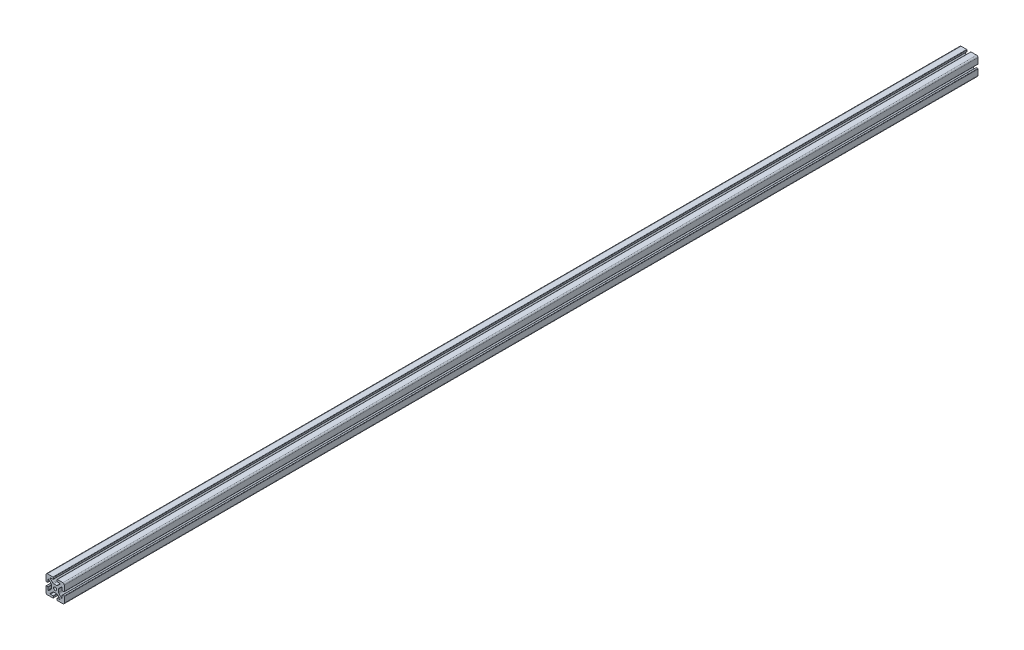
from build123d import *

# Parameters (mm, degrees)
SKETCH1_R           = 3.4036
BOSS_EXTRUDE1_DEPTH = 1000


with BuildPart() as part:
    # Sketch1 → Boss-Extrude1 (new body, symmetric)
    with BuildSketch(Plane.XY):
        with BuildLine():
            Line((-20, 16.952), (-20, 4.7625))
            ThreePointArc((-20, 4.7625), (-19.776815367, 4.223684633), (-19.238, 4.0005))
            Line((-19.238, 4.0005), (-16.2662, 4.0005))
            ThreePointArc((-16.2662, 4.0005), (-15.727384633, 4.223684633), (-15.5042, 4.7625))
            Line((-15.5042, 4.7625), (-15.5042, 10.2235))
            ThreePointArc((-15.5042, 10.2235), (-15.033804775, 10.927496204), (-14.203384633, 10.762315367))
            Line((-14.203384633, 10.762315367), (-8.635059555, 5.19399029))
            ThreePointArc((-8.635059555, 5.19399029), (-7.985348265, 4.221628629), (-7.7572, 3.074649845))
            Line((-7.7572, 3.074649845), (-7.7572, -3.074649845))
            ThreePointArc((-7.7572, -3.074649845), (-7.985348265, -4.221628629), (-8.635059555, -5.19399029))
            Line((-8.635059555, -5.19399029), (-14.203384633, -10.762315367))
            ThreePointArc((-14.203384633, -10.762315367), (-15.033804775, -10.927496204), (-15.5042, -10.2235))
            Line((-15.5042, -10.2235), (-15.5042, -4.7625))
            ThreePointArc((-15.5042, -4.7625), (-15.727384633, -4.223684633), (-16.2662, -4.0005))
            Line((-16.2662, -4.0005), (-19.238, -4.0005))
            ThreePointArc((-19.238, -4.0005), (-19.776815367, -4.223684633), (-20, -4.7625))
            Line((-20, -4.7625), (-20, -16.952))
            ThreePointArc((-20, -16.952), (-19.107261469, -19.107261469), (-16.952, -20))
            Line((-16.952, -20), (-4.7625, -20))
            ThreePointArc((-4.7625, -20), (-4.223684633, -19.776815367), (-4.0005, -19.238))
            Line((-4.0005, -19.238), (-4.0005, -16.2662))
            ThreePointArc((-4.0005, -16.2662), (-4.223684633, -15.727384633), (-4.7625, -15.5042))
            Line((-4.7625, -15.5042), (-10.2235, -15.5042))
            ThreePointArc((-10.2235, -15.5042), (-10.927496204, -15.033804775), (-10.762315367, -14.203384633))
            Line((-10.762315367, -14.203384633), (-5.19399029, -8.635059555))
            ThreePointArc((-5.19399029, -8.635059555), (-4.221628629, -7.985348265), (-3.074649845, -7.7572))
            Line((-3.074649845, -7.7572), (3.074649845, -7.7572))
            ThreePointArc((3.074649845, -7.7572), (4.221628629, -7.985348265), (5.19399029, -8.635059555))
            Line((5.19399029, -8.635059555), (10.762315367, -14.203384633))
            ThreePointArc((10.762315367, -14.203384633), (10.927496204, -15.033804775), (10.2235, -15.5042))
            Line((10.2235, -15.5042), (4.7625, -15.5042))
            ThreePointArc((4.7625, -15.5042), (4.223684633, -15.727384633), (4.0005, -16.2662))
            Line((4.0005, -16.2662), (4.0005, -19.238))
            ThreePointArc((4.0005, -19.238), (4.223684633, -19.776815367), (4.7625, -20))
            Line((4.7625, -20), (16.952, -20))
            ThreePointArc((16.952, -20), (19.107261469, -19.107261469), (20, -16.952))
            Line((20, -16.952), (20, -4.7625))
            ThreePointArc((20, -4.7625), (19.776815367, -4.223684633), (19.238, -4.0005))
            Line((19.238, -4.0005), (16.2662, -4.0005))
            ThreePointArc((16.2662, -4.0005), (15.727384633, -4.223684633), (15.5042, -4.7625))
            Line((15.5042, -4.7625), (15.5042, -10.2235))
            ThreePointArc((15.5042, -10.2235), (15.033804775, -10.927496204), (14.203384633, -10.762315367))
            Line((14.203384633, -10.762315367), (8.635059555, -5.19399029))
            ThreePointArc((8.635059555, -5.19399029), (7.985348265, -4.221628629), (7.7572, -3.074649845))
            Line((7.7572, -3.074649845), (7.7572, 3.074649845))
            ThreePointArc((7.7572, 3.074649845), (7.985348265, 4.221628629), (8.635059555, 5.19399029))
            Line((8.635059555, 5.19399029), (14.203384633, 10.762315367))
            ThreePointArc((14.203384633, 10.762315367), (15.033804775, 10.927496204), (15.5042, 10.2235))
            Line((15.5042, 10.2235), (15.5042, 4.7625))
            ThreePointArc((15.5042, 4.7625), (15.727384633, 4.223684633), (16.2662, 4.0005))
            Line((16.2662, 4.0005), (19.238, 4.0005))
            ThreePointArc((19.238, 4.0005), (19.776815367, 4.223684633), (20, 4.7625))
            Line((20, 4.7625), (20, 16.952))
            ThreePointArc((20, 16.952), (19.107261469, 19.107261469), (16.952, 20))
            Line((16.952, 20), (4.7625, 20))
            ThreePointArc((4.7625, 20), (4.223684633, 19.776815367), (4.0005, 19.238))
            Line((4.0005, 19.238), (4.0005, 16.2662))
            ThreePointArc((4.0005, 16.2662), (4.223684633, 15.727384633), (4.7625, 15.5042))
            Line((4.7625, 15.5042), (10.2235, 15.5042))
            ThreePointArc((10.2235, 15.5042), (10.927496204, 15.033804775), (10.762315367, 14.203384633))
            Line((10.762315367, 14.203384633), (5.19399029, 8.635059555))
            ThreePointArc((5.19399029, 8.635059555), (4.221628629, 7.985348265), (3.074649845, 7.7572))
            Line((3.074649845, 7.7572), (-3.074649845, 7.7572))
            ThreePointArc((-3.074649845, 7.7572), (-4.221628629, 7.985348265), (-5.19399029, 8.635059555))
            Line((-5.19399029, 8.635059555), (-10.762315367, 14.203384633))
            ThreePointArc((-10.762315367, 14.203384633), (-10.927496204, 15.033804775), (-10.2235, 15.5042))
            Line((-10.2235, 15.5042), (-4.7625, 15.5042))
            ThreePointArc((-4.7625, 15.5042), (-4.223684633, 15.727384633), (-4.0005, 16.2662))
            Line((-4.0005, 16.2662), (-4.0005, 19.238))
            ThreePointArc((-4.0005, 19.238), (-4.223684633, 19.776815367), (-4.7625, 20))
            Line((-4.7625, 20), (-16.952, 20))
            ThreePointArc((-16.952, 20), (-19.107261469, 19.107261469), (-20, 16.952))
        make_face()
        Circle(SKETCH1_R, mode=Mode.SUBTRACT)
    extrude(amount=BOSS_EXTRUDE1_DEPTH, both=True)


solid = part.part
